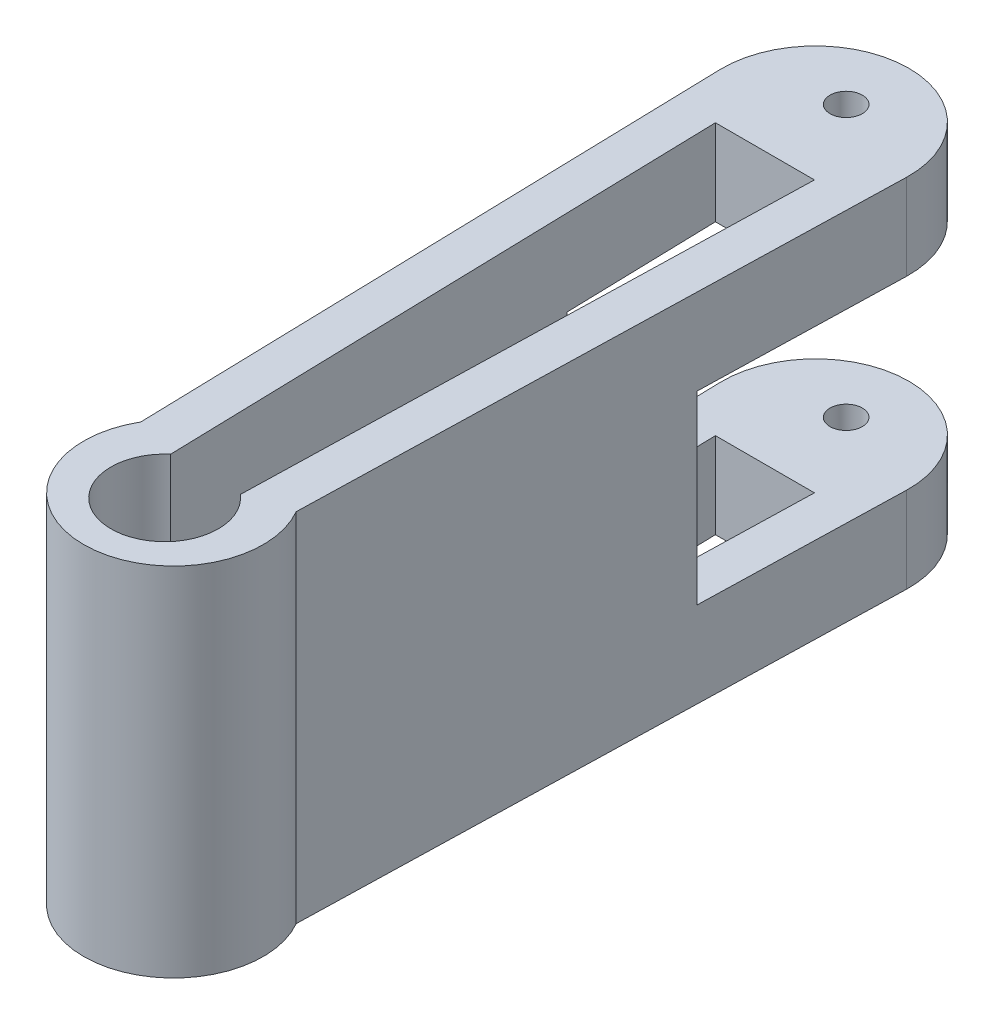
from build123d import *

# Parameters (mm, degrees)
BOSS_EXTRUDE1_DEPTH = 53.34
SKETCH4_W           = 61.072672184
SKETCH4_H           = 27.686
CUT_EXTRUDE3_DEPTH  = 29.259495037
SKETCH5_OUTSIDE_W   = 57.352
SKETCH5_OUTSIDE_H   = 152.814
CUT_EXTRUDE5_DEPTH  = 54.34
SKETCH6_R           = 2.413
CUT_EXTRUDE6_DEPTH  = 54.34


with BuildPart() as part:
    # Sketch1 → Boss-Extrude1 (new body)
    with BuildSketch(Plane(origin=(0, 0, 0), x_dir=(1, 0, 0), z_dir=(0, 1, 0))):
        with BuildLine():
            Line((-13.944778991, -0.365156889), (-11.616850564, -89.265156889))
            ThreePointArc((-11.616850564, -89.265156889), (0, -109.412099434), (11.616850564, -89.265156889))
            Line((11.616850564, -89.265156889), (13.944778991, -0.365156889))
            ThreePointArc((13.944778991, -0.365156889), (0, 13.949559157), (-13.944778991, -0.365156889))
        make_face()
    extrude(amount=BOSS_EXTRUDE1_DEPTH)

    # Sketch4 → Cut-Extrude3 (cut, through all)
    with BuildSketch(Plane(origin=(13.944778991, 0, 0.365156889), x_dir=(0.026176948, 0, -0.999657325), z_dir=(0.999657325, 0, 0.026176948))):
        with Locations((0, 26.67)):
            Rectangle(SKETCH4_W, SKETCH4_H)
    extrude(amount=-CUT_EXTRUDE3_DEPTH, mode=Mode.SUBTRACT)

    # Sketch5 outside → Cut-Extrude5 (cut, through all)
    with BuildSketch(Plane(origin=(0, 53.34, 0), x_dir=(1, 0, 0), z_dir=(0, 1, 0))):
        with Locations((0, -47.731)):
            Rectangle(SKETCH5_OUTSIDE_W, SKETCH5_OUTSIDE_H)
        with BuildLine():
            Line((-13.944778991, -0.365156889), (-11.616850564, -89.265156889))
            ThreePointArc((-11.616850564, -89.265156889), (0, -109.412099434), (11.616850564, -89.265156889))
            Line((11.616850564, -89.265156889), (13.944778991, -0.365156889))
            ThreePointArc((13.944778991, -0.365156889), (0, 13.949559157), (-13.944778991, -0.365156889))
        make_face(mode=Mode.SUBTRACT)
        with BuildLine():
            Line((7.403977553, -7.568443783), (5.213735587, -91.210409969))
            ThreePointArc((5.213735587, -91.210409969), (0, -105.33899845), (-5.213735587, -91.210409969))
            Line((-5.213735587, -91.210409969), (-7.403977553, -7.568443783))
            Line((-7.403977553, -7.568443783), (7.403977553, -7.568443783))
        make_face()
    extrude(amount=-CUT_EXTRUDE5_DEPTH, mode=Mode.SUBTRACT)

    # Sketch6 → Cut-Extrude6 (cut, through all)
    with BuildSketch(Plane(origin=(0, 53.34, 0), x_dir=(1, 0, 0), z_dir=(0, 1, 0))):
        with Locations((0, 4.57874024)):
            Circle(SKETCH6_R)
    extrude(amount=-CUT_EXTRUDE6_DEPTH, mode=Mode.SUBTRACT)


solid = part.part
